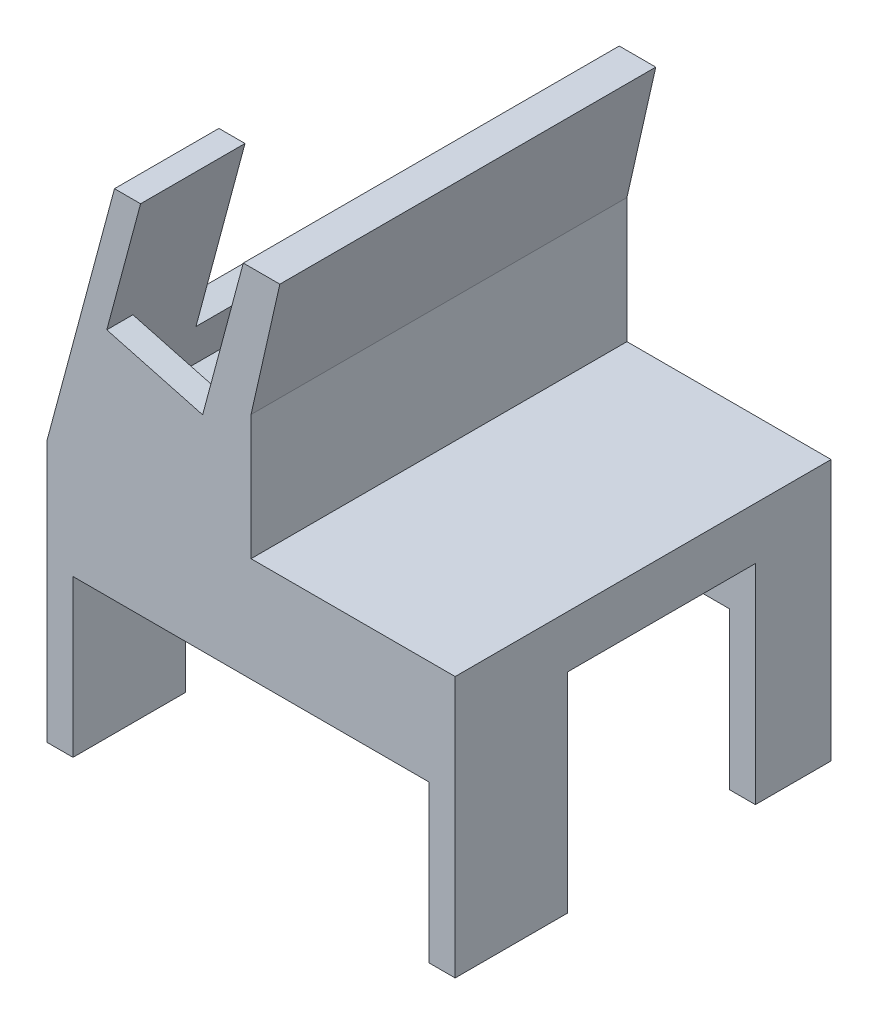
from build123d import *

# Parameters (mm, degrees)
EXTRUDE_1_DEPTH     = 72
SKETCH_2_W          = 68.186813186
SKETCH_2_H          = 36
CUT_EXTRUDE_1_DEPTH = 10
SKETCH_3_W          = 5
SKETCH_3_H          = 36
CUT_EXTRUDE_3_DEPTH = 40
SKETCH_4_W          = 5
SKETCH_4_H          = 36
CUT_EXTRUDE_4_DEPTH = 40
EXTRUDE_2_DEPTH     = 5
EXTRUDE_3_DEPTH     = 67
SKETCH_8_W          = 52
SKETCH_8_H          = 38.074034261
CUT_EXTRUDE_5_DEPTH = 5


with BuildPart() as part:
    # 草圖1 → 填料-伸長1 (new body)
    with BuildSketch(Plane.XY):
        Polygon((-56.41038016, 13.571428571), (-56.41038016, -36.428571429), (-51.41038016, -36.428571429), (-51.41038016, -6.428571429), (16.776433026, -6.428571429), (16.776433026, -36.428571429), (21.776433026, -36.428571429), (21.776433026, 13.571428571), align=None)
    extrude(amount=EXTRUDE_1_DEPTH)

    # 草圖2 → 除料-伸長1 (cut)
    with BuildSketch(Plane.XZ.offset(6.428571429)):
        with Locations((-17.316973567, 32.5)):
            Rectangle(SKETCH_2_W, SKETCH_2_H)
    extrude(amount=-CUT_EXTRUDE_1_DEPTH, mode=Mode.SUBTRACT)

    # 草圖3 → 除料-伸長3 (cut)
    with BuildSketch(Plane.XZ.offset(36.428571429)):
        with Locations((-53.91038016, 32.5)):
            Rectangle(SKETCH_3_W, SKETCH_3_H)
    extrude(amount=-CUT_EXTRUDE_3_DEPTH, mode=Mode.SUBTRACT)

    # 草圖4 → 除料-伸長4 (cut)
    with BuildSketch(Plane.XZ.offset(36.428571429)):
        with Locations((19.276433026, 32.5)):
            Rectangle(SKETCH_4_W, SKETCH_4_H)
    extrude(amount=-CUT_EXTRUDE_4_DEPTH, mode=Mode.SUBTRACT)

    # 草圖5 → 填料-伸長2 (add)
    with BuildSketch(Plane.XY.offset(72)):
        Polygon((-56.41038016, 13.571428571), (-43.469427905, 61.867719886), (-38.469427905, 61.867719886), (-44.939904033, 37.719574229), (-26.587313333, 32.802012372), (-18.799180477, 61.867719886), (-11.799180477, 61.867719886), (-17.316973567, 37.484242705), (-17.316973567, 13.571428571), align=None)
    extrude(amount=-EXTRUDE_2_DEPTH)

    # 草圖7 → 填料-伸長3 (add)
    with BuildSketch(Plane(origin=(0, 0, 67), x_dir=(-1, 0, 0), z_dir=(0, 0, -1))):
        Polygon((17.316973567, 13.571428571), (31.740132733, 13.571428571), (26.587313333, 32.802012372), (18.799180477, 61.867719886), (11.799180477, 61.867719886), (17.316973567, 37.484242705), align=None)
        Polygon((31.740132733, 13.571428571), (56.41038016, 13.571428571), (43.469427905, 61.867719886), (38.469427905, 61.867719886), (44.939904033, 37.719574229), (50.092723432, 18.488990428), align=None)
    extrude(amount=EXTRUDE_3_DEPTH)

    # 草圖8 → 除料-伸長5 (cut)
    with BuildSketch(Plane(origin=(-56.024458351, 15.011708372, 0), x_dir=(0, 0, 1), z_dir=(-0.965925826, 0.258819045, 0))):
        with Locations((26, 32.545929761)):
            Rectangle(SKETCH_8_W, SKETCH_8_H)
    extrude(amount=-CUT_EXTRUDE_5_DEPTH, mode=Mode.SUBTRACT)


solid = part.part
